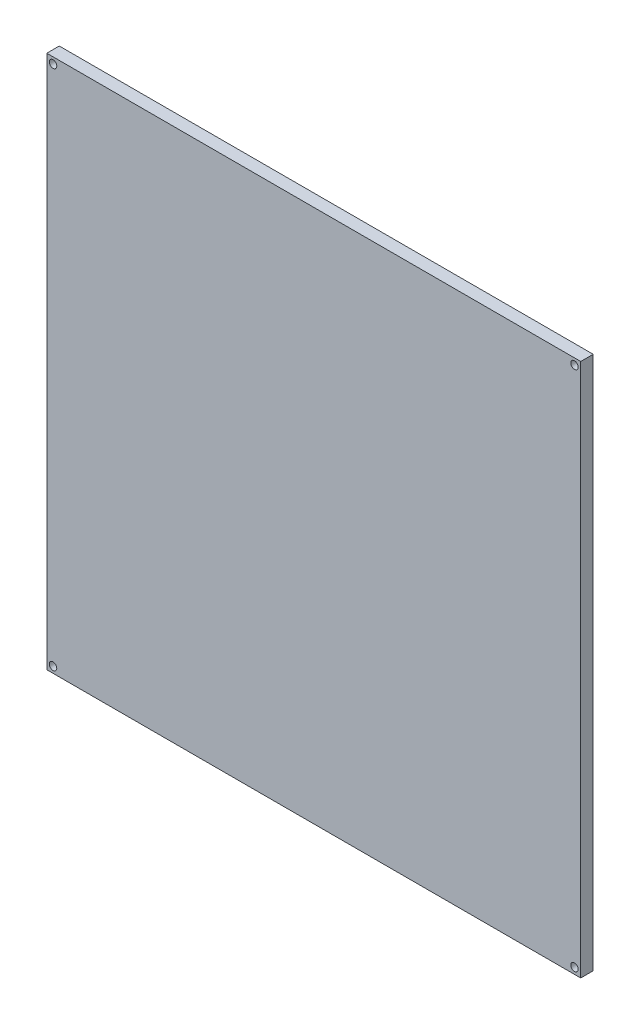
from build123d import *

# Parameters (mm, degrees)
SCHIZZO1_W                   = 214
SCHIZZO1_H                   = 214
SCHIZZO1_R                   = 1.5
ESTRUSIONE_ESTRUSIONE1_DEPTH = 5


with BuildPart() as part:
    # Schizzo1 → Estrusione-Estrusione1 (new body)
    with BuildSketch(Plane.XY):
        with Locations((107, 107)):
            Rectangle(SCHIZZO1_W, SCHIZZO1_H)
        with Locations((2.5, 211.5)):
            Circle(SCHIZZO1_R, mode=Mode.SUBTRACT)
        with Locations((211.5, 211.5)):
            Circle(SCHIZZO1_R, mode=Mode.SUBTRACT)
        with Locations((2.5, 2.5)):
            Circle(SCHIZZO1_R, mode=Mode.SUBTRACT)
        with Locations((211.5, 2.5)):
            Circle(SCHIZZO1_R, mode=Mode.SUBTRACT)
    extrude(amount=-ESTRUSIONE_ESTRUSIONE1_DEPTH)


solid = part.part
